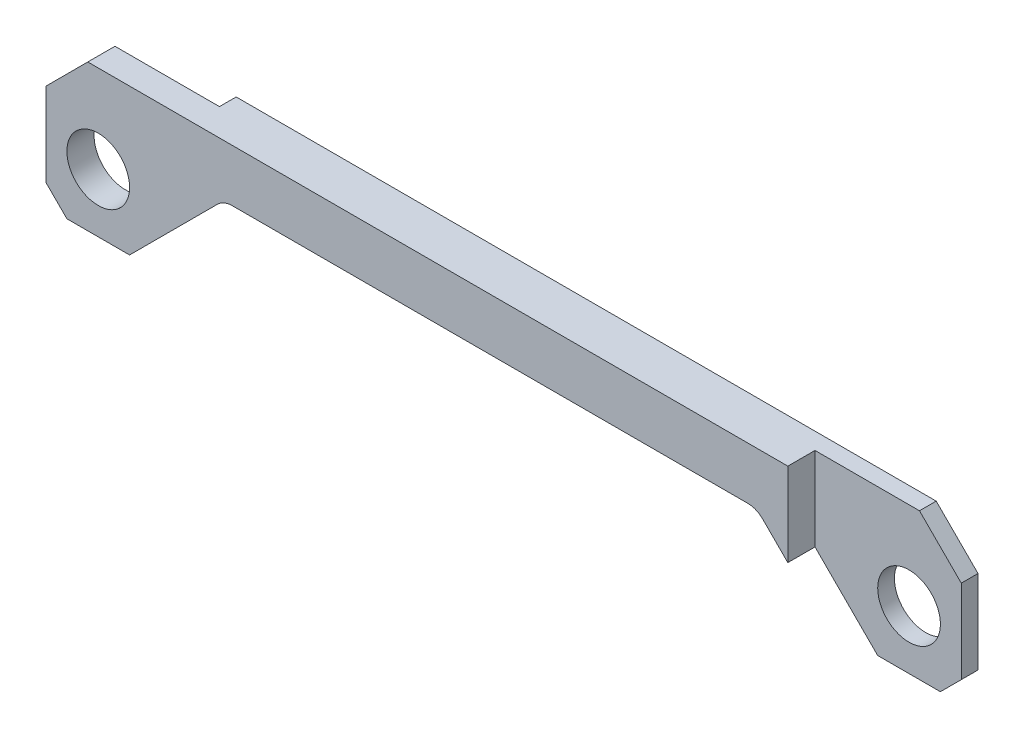
from build123d import *

# Parameters (mm, degrees)
SKETCH4_R       = 38.1
BASE_DEPTH      = 53.34
SKETCH5_W       = 177.8
SKETCH5_H       = 20.32
SKETCH5_H_2     = 33.02
SIDE_CUTS_DEPTH = 178.8
BOTTOM_FILLET_R = 25.4


with BuildPart() as part:
    # Sketch4 → Base (new body)
    with BuildSketch(Plane.XY):
        Polygon((38.1, -71.12), (-38.1, -71.12), (-63.5, -45.72), (-63.5, 55.88), (-12.7, 106.68), (965.2, 106.68), (1016, 55.88), (1016, -45.72), (990.6, -71.12), (914.4, -71.12), (800.1, 43.18), (152.4, 43.18), align=None)
        Circle(SKETCH4_R, mode=Mode.SUBTRACT)
        with Locations((952.5, 0)):
            Circle(SKETCH4_R, mode=Mode.SUBTRACT)
    extrude(amount=BASE_DEPTH)

    # Sketch5 → side cuts (cut, through all)
    with BuildSketch(Plane(origin=(0, 106.68, 0), x_dir=(1, 0, 0), z_dir=(0, 1, 0))):
        with Locations((25.4, -10.16)):
            Rectangle(SKETCH5_W, SKETCH5_H)
        with Locations((927.1, -36.83)):
            Rectangle(SKETCH5_W, SKETCH5_H_2)
    extrude(amount=-SIDE_CUTS_DEPTH, mode=Mode.SUBTRACT)

    # bottom fillet
    bottom_fillet_edges = [part.edges().sort_by_distance(p)[0] for p in [
        (800.1, 43.18, 26.67),
        (152.4, 43.18, 26.67),
    ]]
    fillet(bottom_fillet_edges, radius=BOTTOM_FILLET_R)


solid = part.part
